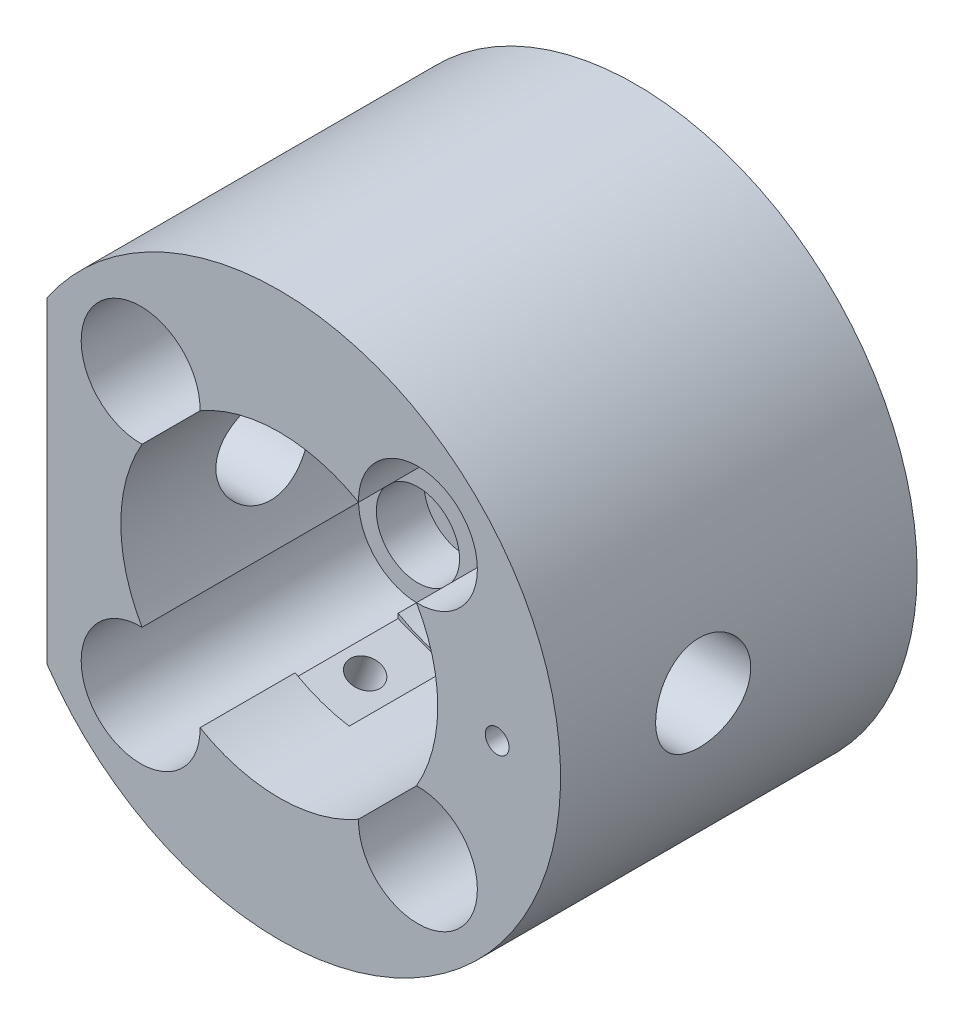
from build123d import *
from build123d.topology import SkipClean

# Parameters (mm, degrees)
CROQUIS1_R                   = 35.5
CROQUIS1_R_2                 = 3.25
CROQUIS1_R_3                 = 3.15
SALIENTE_EXTRUIR1_DEPTH      = 5
SALIENTE_EXTRUIR2_DEPTH      = 35
CROQUIS3_R                   = 6
CORTAR_EXTRUIR1_DEPTH        = 85.042735149
CORTAR_EXTRUIR2_REACH        = 66.191
CORTAR_EXTRUIR2_END_RADIUS   = 6
CROQUIS4_R                   = 1.5
CORTAR_EXTRUIR_L_MINA1_START = 11
CORTAR_EXTRUIR_L_MINA1_DEPTH = 13
CORTAR_EXTRUIR3_REACH        = 94.695
CORTAR_EXTRUIR3_END_RADIUS   = 20
CROQUIS6_R                   = 2
CORTAR_EXTRUIR_L_MINA2_START = 10
CORTAR_EXTRUIR_L_MINA2_DEPTH = 13
CROQUIS10_R                  = 35.5
CROQUIS10_R_2                = 3.25
CROQUIS10_R_3                = 3.15
SALIENTE_EXTRUIR4_DEPTH      = 5
CROQUIS8_R                   = 5.25
CORTAR_EXTRUIR4_DEPTH        = 6


with BuildPart() as part:
    # Croquis1 → Saliente-Extruir1 (new body)
    with BuildSketch(Plane.XY):
        Circle(CROQUIS1_R)
        Circle(CROQUIS1_R_2, mode=Mode.SUBTRACT)
        with Locations((17.500892834, 17.500892834)):
            Circle(CROQUIS1_R_3, mode=Mode.SUBTRACT)
        with Locations((17.500892834, -17.500892834)):
            Circle(CROQUIS1_R_3, mode=Mode.SUBTRACT)
        with Locations((-17.500892834, -17.500892834)):
            Circle(CROQUIS1_R_3, mode=Mode.SUBTRACT)
        with Locations((-17.500892834, 17.500892834)):
            Circle(CROQUIS1_R_3, mode=Mode.SUBTRACT)
    extrude(amount=SALIENTE_EXTRUIR1_DEPTH)

    # Croquis2 → Saliente-Extruir2 (add)
    with BuildSketch(Plane.XY.offset(5)):
        with BuildLine():
            ThreePointArc((-29.330018752, -20), (35.5, 0), (-29.330018752, 20))
            Line((-29.330018752, 20), (-29.330018752, -20))
        make_face()
        with BuildLine():
            ThreePointArc((10.003105755, 17.318714596), (17.409796995, 25.000339584), (25.000892834, 17.500892834))
            ThreePointArc((25.000892834, 17.500892834), (22.739388001, 12.133568697), (17.318714596, 10.003105755))
            ThreePointArc((17.318714596, 10.003105755), (19.318052333, 5.178112981), (20, 0))
            ThreePointArc((20, 0), (19.318052333, -5.178112981), (17.318714596, -10.003105755))
            ThreePointArc((17.318714596, -10.003105755), (22.739388001, -12.133568697), (25.000892834, -17.500892834))
            ThreePointArc((25.000892834, -17.500892834), (17.409796995, -25.000339584), (10.003105755, -17.318714596))
            ThreePointArc((10.003105755, -17.318714596), (0, -20), (-10.003105755, -17.318714596))
            ThreePointArc((-10.003105755, -17.318714596), (-10.001446085, -17.409796995), (-10.000892834, -17.500892834))
            ThreePointArc((-10.000892834, -17.500892834), (-22.868216972, -22.739388001), (-17.318714596, -10.003105755))
            ThreePointArc((-17.318714596, -10.003105755), (-20, 0), (-17.318714596, 10.003105755))
            ThreePointArc((-17.318714596, 10.003105755), (-22.868216972, 22.739388001), (-10.000892834, 17.500892834))
            ThreePointArc((-10.000892834, 17.500892834), (-10.001446085, 17.409796995), (-10.003105755, 17.318714596))
            ThreePointArc((-10.003105755, 17.318714596), (0, 20), (10.003105755, 17.318714596))
        make_face(mode=Mode.SUBTRACT)
    extrude(amount=SALIENTE_EXTRUIR2_DEPTH)

    # Croquis3 → Cortar-Extruir1 (cut, through all)
    with SkipClean():  # the faces are left unmerged after this step: merging them gives an invalid solid
        with BuildSketch(Plane.ZY.offset(29.330018752)):
            with Locations((22, 0)):
                Circle(CROQUIS3_R)
        extrude(amount=-CORTAR_EXTRUIR1_DEPTH, mode=Mode.SUBTRACT)

    # Cortar-Extruir2: up to this cylinder (the profile starts outside it)
    with SkipClean():  # the faces are left unmerged after this step: merging them gives an invalid solid
        cortar_extruir2_end = Plane(origin=(27.5, 0, 22), z_dir=(-1, 0, 0)) * Cylinder(CORTAR_EXTRUIR2_END_RADIUS, 145.382, mode=Mode.PRIVATE)
        # Croquis4 → Cortar-Extruir2 (cut, up to the surface)
        with BuildSketch(Plane.XY.offset(40), mode=Mode.PRIVATE) as cortar_extruir2_sk1:
            with Locations((27.5, 0)):
                Circle(CROQUIS4_R)
        cortar_extruir2_tool1 = extrude(cortar_extruir2_sk1.sketch, amount=-CORTAR_EXTRUIR2_REACH, mode=Mode.PRIVATE) - cortar_extruir2_end
        add(cortar_extruir2_tool1.solids().sort_by_distance((27.5, 0, 40))[0], mode=Mode.SUBTRACT)

    # Croquis5 → Cortar-Extruir-L_mina1 (cut)
    with SkipClean():  # the faces are left unmerged after this step: merging them gives an invalid solid
        with BuildSketch(Plane.XY.offset(5).offset(CORTAR_EXTRUIR_L_MINA1_START)):
            Polygon((-16.202076443, -31.58706569), (-8.717795145, -34.41293431), (-9.4242623, -36.284004634), (-16.908543598, -33.458136015), align=None)
        extrude(amount=CORTAR_EXTRUIR_L_MINA1_DEPTH, mode=Mode.SUBTRACT)

    # Cortar-Extruir3: up to this cylinder (the profile starts outside it)
    with SkipClean():  # the faces are left unmerged after this step: merging them gives an invalid solid
        cortar_extruir3_end = Plane(origin=(0, 0, 22), z_dir=(0, 0, -1)) * Cylinder(CORTAR_EXTRUIR3_END_RADIUS, 230.39, mode=Mode.PRIVATE)
        # Croquis6 → Cortar-Extruir3 (cut, up to the surface)
        with BuildSketch(Plane(origin=(-12.459935794, -33, 0), x_dir=(0.935535162237637, -0.3532335774200951, 0), z_dir=(-0.35323357742009515, -0.9355351622376371, 0)), mode=Mode.PRIVATE) as cortar_extruir3_sk1:
            with Locations((0, 22)):
                Circle(CROQUIS6_R)
        cortar_extruir3_tool1 = extrude(cortar_extruir3_sk1.sketch, amount=-CORTAR_EXTRUIR3_REACH, mode=Mode.PRIVATE) - cortar_extruir3_end
        add(cortar_extruir3_tool1.solids().sort_by_distance((-12.459936, -33, 22))[0], mode=Mode.SUBTRACT)

    # Croquis7 → Cortar-Extruir-L_mina2 (cut)
    with SkipClean():  # the faces are left unmerged after this step: merging them gives an invalid solid
        with BuildSketch(Plane.XY.offset(5).offset(CORTAR_EXTRUIR_L_MINA2_START)):
            Polygon((-10.903572782, -17.554038257), (-3.419291484, -20.379906876), (-2.712824329, -18.508836552), (-10.197105627, -15.682967932), align=None)
        extrude(amount=CORTAR_EXTRUIR_L_MINA2_DEPTH, mode=Mode.SUBTRACT)

    # Croquis10 → Saliente-Extruir4 (add)
    with SkipClean():  # the faces are left unmerged after this step: merging them gives an invalid solid
        with BuildSketch(Plane(origin=(0, 0, 0), x_dir=(-1, 0, 0), z_dir=(0, 0, -1))):
            Circle(CROQUIS10_R)
            Circle(CROQUIS10_R_2, mode=Mode.SUBTRACT)
            with Locations((-17.500892834, -17.500892834)):
                Circle(CROQUIS10_R_3, mode=Mode.SUBTRACT)
            with Locations((17.500892834, 17.500892834)):
                Circle(CROQUIS10_R_3, mode=Mode.SUBTRACT)
            with Locations((17.500892834, -17.500892834)):
                Circle(CROQUIS10_R_3, mode=Mode.SUBTRACT)
            with Locations((-17.500892834, 17.500892834)):
                Circle(CROQUIS10_R_3, mode=Mode.SUBTRACT)
        extrude(amount=SALIENTE_EXTRUIR4_DEPTH)

    # Croquis8 → Cortar-Extruir4 (cut)
    with SkipClean():  # the faces are left unmerged after this step: merging them gives an invalid solid
        with BuildSketch(Plane.XY.offset(5)):
            with Locations((-17.500892834, -17.500892834)):
                Circle(CROQUIS8_R)
            with Locations((-17.500892834, 17.500892834)):
                Circle(CROQUIS8_R)
            with Locations((17.500892834, 17.500892834)):
                Circle(CROQUIS8_R)
            with Locations((17.500892834, -17.500892834)):
                Circle(CROQUIS8_R)
        extrude(amount=-CORTAR_EXTRUIR4_DEPTH, mode=Mode.SUBTRACT)


solid = part.part
